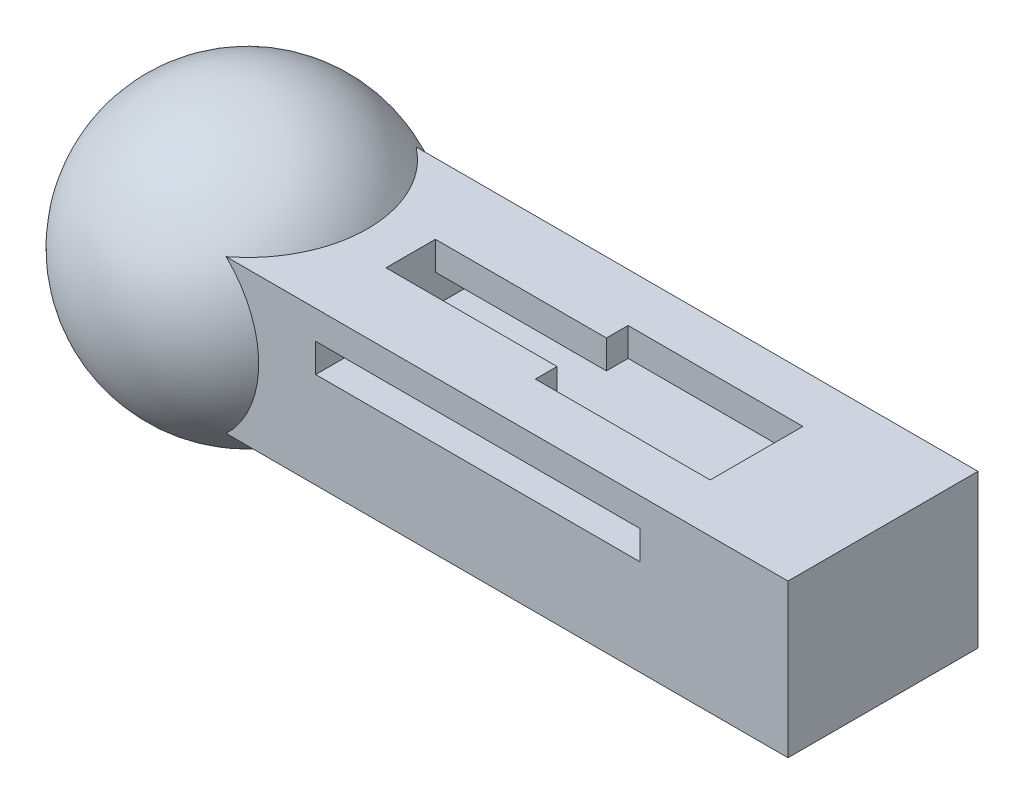
from build123d import *

# Parameters (mm, degrees)
CROQUIS2_W              = 26.743660572
CROQUIS2_H              = 8.055392927
CROQUIS2_W_2            = 17.066952721
CROQUIS2_H_2            = 4.555392927
SALIENTE_EXTRUIR1_DEPTH = 5
CORTAR_EXTRUIR1_DEPTH   = 6.055393
SALIENTE_EXTRUIR2_DEPTH = 3.04
CROQUIS7_W              = 10
CROQUIS7_H              = 8.055392927
SALIENTE_EXTRUIR3_DEPTH = 3.04


with BuildPart() as part:
    # Croquis2 → Saliente-Extruir1 (new body, symmetric)
    with BuildSketch(Plane.XY):
        with Locations((11.482548502, 2.027696464)):
            Rectangle(CROQUIS2_W, CROQUIS2_H)
        with Locations((8.53347636, 2.277696464)):
            Rectangle(CROQUIS2_W_2, CROQUIS2_H_2, mode=Mode.SUBTRACT)
    extrude(amount=SALIENTE_EXTRUIR1_DEPTH, both=True)

    # Croquis3 → Cortar-Extruir1 (cut)
    with BuildSketch(Plane(origin=(0, 6.055392927, 0), x_dir=(1, 0, 0), z_dir=(0, 1, 0))):
        Polygon((9, -2.44020423), (9, -1.3), (0, -1.3), (0, 1.3), (9, 1.3), (9, 2.44020423), (18.2, 2.44020423), (18.2, -2.44020423), align=None)
    extrude(amount=-CORTAR_EXTRUIR1_DEPTH, mode=Mode.SUBTRACT)

    # Croquis4 → Saliente-Extruir2 (add)
    with BuildSketch(Plane(origin=(0, 0, 0), x_dir=(1, 0, 0), z_dir=(0, 1, 0))):
        Polygon((17.066952721, 5), (0, 5), (0, -5), (17.066952721, -5), (17.066952721, -2.44020423), (18.2, -2.44020423), (18.2, 2.44020423), (17.066952721, 2.44020423), align=None)
    extrude(amount=SALIENTE_EXTRUIR2_DEPTH)

    # Croquis6 → Revolución1 (revolve)
    with BuildSketch(Plane.XY):
        with BuildLine():
            Line((-1.088241608, 2.027696464), (-16.088241608, 2.027696464))
            ThreePointArc((-16.088241608, 2.027696464), (-8.588241608, 9.527696464), (-1.088241608, 2.027696464))
        make_face()
    revolve(axis=Axis((-1.889281784, 2.027696464, 0), (-1, 0, 0)))

    # Croquis7 → Saliente-Extruir3 (add)
    with BuildSketch(Plane.ZY.offset(1.889281784)):
        with Locations((0, 2.027696464)):
            Rectangle(CROQUIS7_W, CROQUIS7_H)
    extrude(amount=SALIENTE_EXTRUIR3_DEPTH)


solid = part.part
